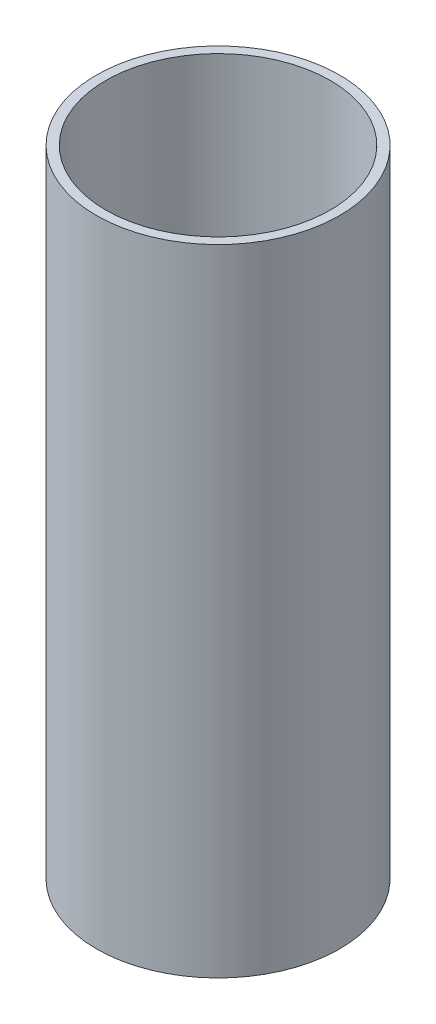
from build123d import *

# Parameters (mm, degrees)
SKETCH1_R           = 82.55
SKETCH1_R_2         = 76.2
BOSS_EXTRUDE1_DEPTH = 215.5


with BuildPart() as part:
    # Sketch1 → Boss-Extrude1 (new body, symmetric)
    with BuildSketch(Plane(origin=(0, 0, 0), x_dir=(1, 0, 0), z_dir=(0, 1, 0))):
        Circle(SKETCH1_R)
        Circle(SKETCH1_R_2, mode=Mode.SUBTRACT)
    extrude(amount=BOSS_EXTRUDE1_DEPTH, both=True)


solid = part.part
